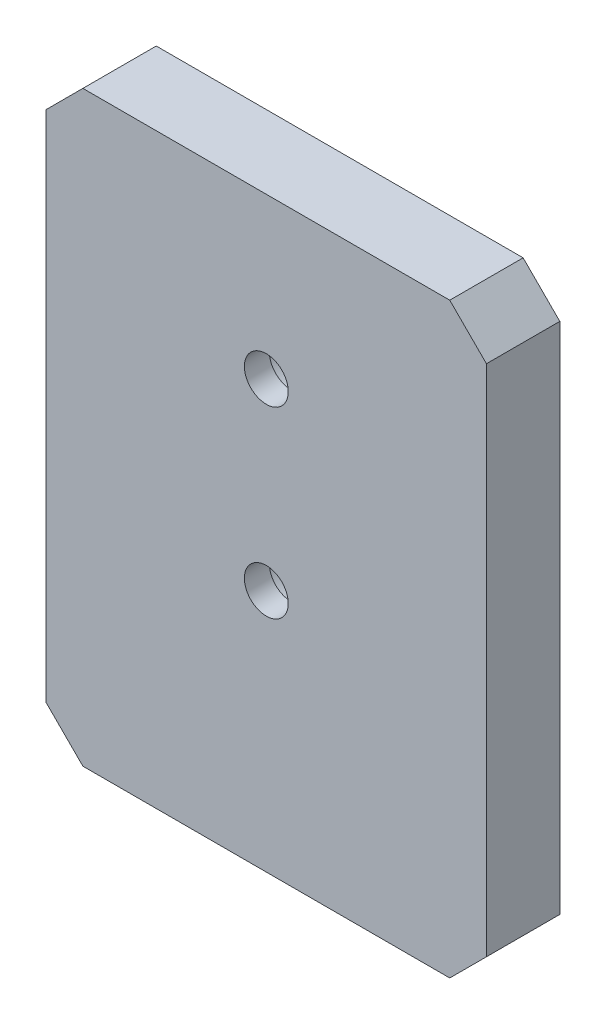
from build123d import *

# Parameters (mm, degrees)
SKETCH1_W                                      = 38.1
SKETCH1_H                                      = 50.8
BOSS_EXTRUDE1_DEPTH                            = 6.35
CHAMFER1_SIZE                                  = 3.175
CBORE_FOR_6_SOCKET_HEAD_CAP_SCREW1_D           = 3.7973
CBORE_FOR_6_SOCKET_HEAD_CAP_SCREW1_CBORE_D     = 7.14502
CBORE_FOR_6_SOCKET_HEAD_CAP_SCREW1_CBORE_DEPTH = 4.191


with BuildPart() as part:
    # Sketch1 → Boss-Extrude1 (new body)
    with BuildSketch(Plane.XY):
        Rectangle(SKETCH1_W, SKETCH1_H)
    extrude(amount=-BOSS_EXTRUDE1_DEPTH)

    # Chamfer1
    chamfer1_edges = [part.edges().sort_by_distance(p)[0] for p in [
        (19.05, -25.4, -3.175),
        (-19.05, -25.4, -3.175),
        (-19.05, 25.4, -3.175),
        (19.05, 25.4, -3.175),
    ]]
    chamfer(chamfer1_edges, length=CHAMFER1_SIZE)

    # CBORE for #6 Socket Head Cap Screw1 (through all)
    with Locations(Plane(origin=(0, 0, -6.35), x_dir=(-1, 0, 0), z_dir=(0, 0, -1))):
        with Locations((0, -4.318), (0, 11.557)):
            CounterBoreHole(CBORE_FOR_6_SOCKET_HEAD_CAP_SCREW1_D / 2, CBORE_FOR_6_SOCKET_HEAD_CAP_SCREW1_CBORE_D / 2, CBORE_FOR_6_SOCKET_HEAD_CAP_SCREW1_CBORE_DEPTH)


solid = part.part
